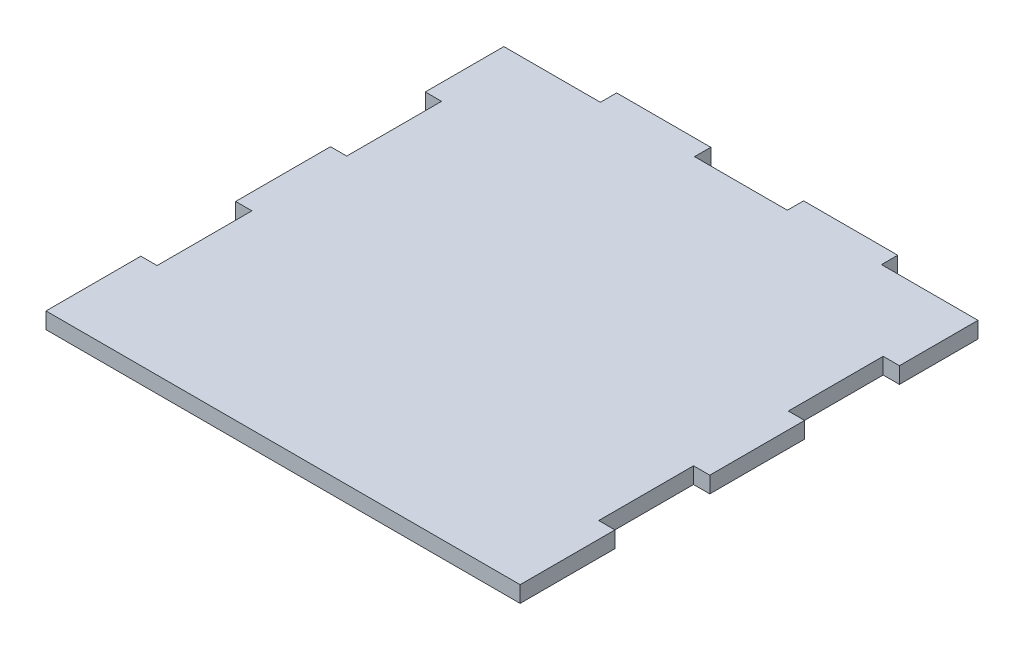
from build123d import *

# Parameters (mm, degrees)
BOSS_EXTRUDE1_DEPTH = 12


with BuildPart() as part:
    # Sketch1 → Boss-Extrude1 (new body)
    with BuildSketch(Plane(origin=(0, 0, 0), x_dir=(1, 0, 0), z_dir=(0, 1, 0))):
        Polygon((350, 280), (338, 280), (338, 210), (350, 210), (350, 140), (338, 140), (338, 70), (350, 70), (350, 0), (0, 0), (0, 70), (12, 70), (12, 140), (0, 140), (0, 210), (12, 210), (12, 280), (0, 280), (0, 338), (71.25, 338), (71.25, 350), (140.75, 350), (140.75, 338), (209.25, 338), (209.25, 350), (278.75, 350), (278.75, 338), (350, 338), align=None)
    extrude(amount=BOSS_EXTRUDE1_DEPTH)


solid = part.part
